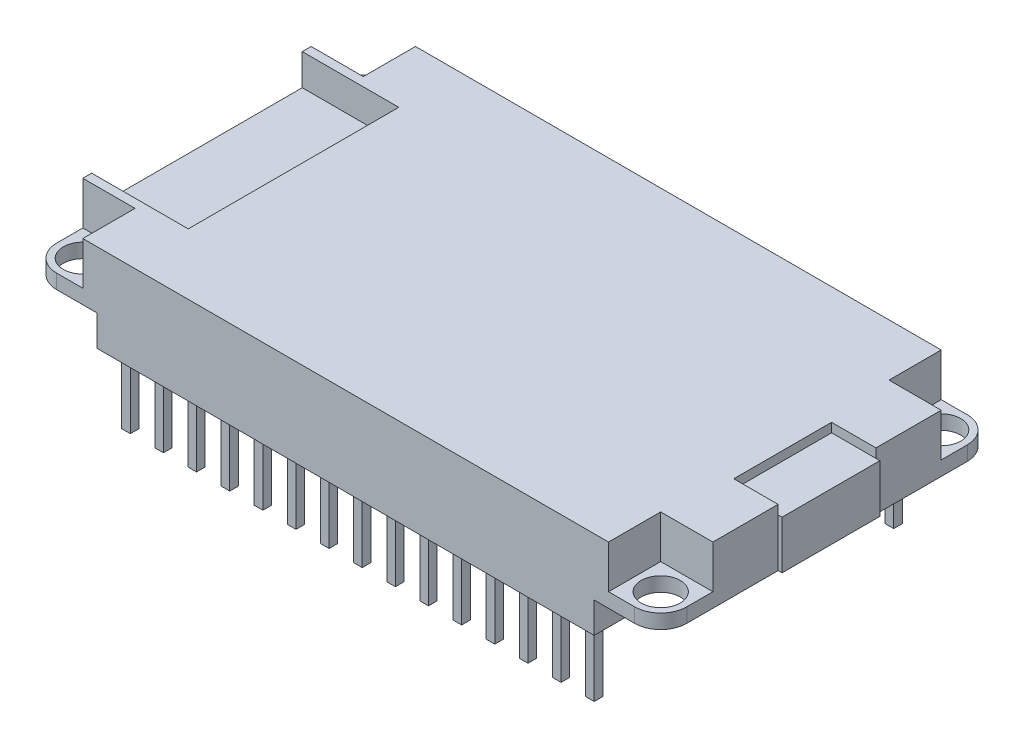
from build123d import *

# Parameters (mm, degrees)
SKETCH1_W           = 48.3
SKETCH1_H           = 25.5
SKETCH1_R           = 1.5
BOSS_EXTRUDE1_DEPTH = 4.4
FILLET1_R           = 2
SKETCH2_W           = 2.54
SKETCH2_H           = 2.54
BOSS_EXTRUDE2_DEPTH = 2.35
SKETCH3_W           = 0.66
SKETCH3_H           = 0.66
BOSS_EXTRUDE3_DEPTH = 5.33
SKETCH4_W           = 3.4
SKETCH4_H           = 7.5
CUT_EXTRUDE1_DEPTH  = 0.7
SKETCH5_W           = 7.5
SKETCH5_H           = 3.7
BOSS_EXTRUDE4_DEPTH = 0.3
SKETCH6_W           = 7.4
SKETCH6_H           = 16.14
CUT_EXTRUDE2_DEPTH  = 2.4
SKETCH7_W           = 4
SKETCH7_H           = 4
CUT_EXTRUDE3_DEPTH  = 3.3


with BuildPart() as part:
    # Sketch1 → Boss-Extrude1 (new body)
    with BuildSketch(Plane(origin=(0, 0, 0), x_dir=(1, 0, 0), z_dir=(0, 1, 0))):
        with Locations((24.15, -12.75)):
            Rectangle(SKETCH1_W, SKETCH1_H)
        with Locations((46.3, -2)):
            Circle(SKETCH1_R, mode=Mode.SUBTRACT)
        with Locations((2, -2)):
            Circle(SKETCH1_R, mode=Mode.SUBTRACT)
        with Locations((46.3, -23.5)):
            Circle(SKETCH1_R, mode=Mode.SUBTRACT)
        with Locations((2, -23.5)):
            Circle(SKETCH1_R, mode=Mode.SUBTRACT)
    extrude(amount=BOSS_EXTRUDE1_DEPTH)

    # Fillet1
    fillet1_edges = [part.edges().sort_by_distance(p)[0] for p in [
        (48.3, 2.2, 25.5),
        (0, 2.2, 25.5),
        (0, 2.2, 0),
        (48.3, 2.2, 0),
    ]]
    fillet(fillet1_edges, radius=FILLET1_R)

    # Sketch2 → Boss-Extrude2 (add)
    with BuildSketch(Plane.XZ):
        with Locations((6.37, 24.23)):
            Rectangle(SKETCH2_W, SKETCH2_H)
        with Locations((8.91, 24.23)):
            Rectangle(SKETCH2_W, SKETCH2_H)
        with Locations((11.45, 24.23)):
            Rectangle(SKETCH2_W, SKETCH2_H)
        with Locations((13.99, 24.23)):
            Rectangle(SKETCH2_W, SKETCH2_H)
        with Locations((16.53, 24.23)):
            Rectangle(SKETCH2_W, SKETCH2_H)
        with Locations((19.07, 24.23)):
            Rectangle(SKETCH2_W, SKETCH2_H)
        with Locations((21.61, 24.23)):
            Rectangle(SKETCH2_W, SKETCH2_H)
        with Locations((24.15, 24.23)):
            Rectangle(SKETCH2_W, SKETCH2_H)
        with Locations((26.69, 24.23)):
            Rectangle(SKETCH2_W, SKETCH2_H)
        with Locations((29.23, 24.23)):
            Rectangle(SKETCH2_W, SKETCH2_H)
        with Locations((31.77, 24.23)):
            Rectangle(SKETCH2_W, SKETCH2_H)
        with Locations((34.31, 24.23)):
            Rectangle(SKETCH2_W, SKETCH2_H)
        with Locations((36.85, 24.23)):
            Rectangle(SKETCH2_W, SKETCH2_H)
        with Locations((39.39, 24.23)):
            Rectangle(SKETCH2_W, SKETCH2_H)
        with Locations((41.93, 24.23)):
            Rectangle(SKETCH2_W, SKETCH2_H)
        with Locations((41.93, 1.27)):
            Rectangle(SKETCH2_W, SKETCH2_H)
        with Locations((39.39, 1.27)):
            Rectangle(SKETCH2_W, SKETCH2_H)
        with Locations((36.85, 1.27)):
            Rectangle(SKETCH2_W, SKETCH2_H)
        with Locations((34.31, 1.27)):
            Rectangle(SKETCH2_W, SKETCH2_H)
        with Locations((31.77, 1.27)):
            Rectangle(SKETCH2_W, SKETCH2_H)
        with Locations((29.23, 1.27)):
            Rectangle(SKETCH2_W, SKETCH2_H)
        with Locations((26.69, 1.27)):
            Rectangle(SKETCH2_W, SKETCH2_H)
        with Locations((24.15, 1.27)):
            Rectangle(SKETCH2_W, SKETCH2_H)
        with Locations((21.61, 1.27)):
            Rectangle(SKETCH2_W, SKETCH2_H)
        with Locations((19.07, 1.27)):
            Rectangle(SKETCH2_W, SKETCH2_H)
        with Locations((16.53, 1.27)):
            Rectangle(SKETCH2_W, SKETCH2_H)
        with Locations((13.99, 1.27)):
            Rectangle(SKETCH2_W, SKETCH2_H)
        with Locations((11.45, 1.27)):
            Rectangle(SKETCH2_W, SKETCH2_H)
        with Locations((8.91, 1.27)):
            Rectangle(SKETCH2_W, SKETCH2_H)
        with Locations((6.37, 1.27)):
            Rectangle(SKETCH2_W, SKETCH2_H)
    extrude(amount=BOSS_EXTRUDE2_DEPTH)

    # Sketch3 → Boss-Extrude3 (add)
    with BuildSketch(Plane.XZ.offset(2.35)):
        with Locations((6.37, 24.23)):
            Rectangle(SKETCH3_W, SKETCH3_H)
        with Locations((8.91, 24.23)):
            Rectangle(SKETCH3_W, SKETCH3_H)
        with Locations((11.45, 24.23)):
            Rectangle(SKETCH3_W, SKETCH3_H)
        with Locations((13.99, 24.23)):
            Rectangle(SKETCH3_W, SKETCH3_H)
        with Locations((16.53, 24.23)):
            Rectangle(SKETCH3_W, SKETCH3_H)
        with Locations((19.07, 24.23)):
            Rectangle(SKETCH3_W, SKETCH3_H)
        with Locations((21.61, 24.23)):
            Rectangle(SKETCH3_W, SKETCH3_H)
        with Locations((24.15, 24.23)):
            Rectangle(SKETCH3_W, SKETCH3_H)
        with Locations((26.69, 24.23)):
            Rectangle(SKETCH3_W, SKETCH3_H)
        with Locations((29.23, 24.23)):
            Rectangle(SKETCH3_W, SKETCH3_H)
        with Locations((31.77, 24.23)):
            Rectangle(SKETCH3_W, SKETCH3_H)
        with Locations((34.31, 24.23)):
            Rectangle(SKETCH3_W, SKETCH3_H)
        with Locations((36.85, 24.23)):
            Rectangle(SKETCH3_W, SKETCH3_H)
        with Locations((39.39, 24.23)):
            Rectangle(SKETCH3_W, SKETCH3_H)
        with Locations((41.93, 24.23)):
            Rectangle(SKETCH3_W, SKETCH3_H)
        with Locations((41.93, 1.27)):
            Rectangle(SKETCH3_W, SKETCH3_H)
        with Locations((39.39, 1.27)):
            Rectangle(SKETCH3_W, SKETCH3_H)
        with Locations((36.85, 1.27)):
            Rectangle(SKETCH3_W, SKETCH3_H)
        with Locations((34.31, 1.27)):
            Rectangle(SKETCH3_W, SKETCH3_H)
        with Locations((31.77, 1.27)):
            Rectangle(SKETCH3_W, SKETCH3_H)
        with Locations((29.23, 1.27)):
            Rectangle(SKETCH3_W, SKETCH3_H)
        with Locations((26.69, 1.27)):
            Rectangle(SKETCH3_W, SKETCH3_H)
        with Locations((24.15, 1.27)):
            Rectangle(SKETCH3_W, SKETCH3_H)
        with Locations((21.61, 1.27)):
            Rectangle(SKETCH3_W, SKETCH3_H)
        with Locations((19.07, 1.27)):
            Rectangle(SKETCH3_W, SKETCH3_H)
        with Locations((16.53, 1.27)):
            Rectangle(SKETCH3_W, SKETCH3_H)
        with Locations((13.99, 1.27)):
            Rectangle(SKETCH3_W, SKETCH3_H)
        with Locations((11.45, 1.27)):
            Rectangle(SKETCH3_W, SKETCH3_H)
        with Locations((8.91, 1.27)):
            Rectangle(SKETCH3_W, SKETCH3_H)
        with Locations((6.37, 1.27)):
            Rectangle(SKETCH3_W, SKETCH3_H)
    extrude(amount=BOSS_EXTRUDE3_DEPTH)

    # Sketch4 → Cut-Extrude1 (cut)
    with BuildSketch(Plane(origin=(0, 4.4, 0), x_dir=(1, 0, 0), z_dir=(0, 1, 0))):
        with Locations((46.6, -12.75)):
            Rectangle(SKETCH4_W, SKETCH4_H)
    extrude(amount=-CUT_EXTRUDE1_DEPTH, mode=Mode.SUBTRACT)

    # Sketch5 → Boss-Extrude4 (add)
    with BuildSketch(Plane(origin=(48.3, 0, 0), x_dir=(0, 0, -1), z_dir=(1, 0, 0))):
        with Locations((-12.75, 1.85)):
            Rectangle(SKETCH5_W, SKETCH5_H)
    extrude(amount=BOSS_EXTRUDE4_DEPTH)

    # Sketch6 → Cut-Extrude2 (cut)
    with BuildSketch(Plane(origin=(0, 4.4, 0), x_dir=(1, 0, 0), z_dir=(0, 1, 0))):
        with Locations((3.7, -12.75)):
            Rectangle(SKETCH6_W, SKETCH6_H)
    extrude(amount=-CUT_EXTRUDE2_DEPTH, mode=Mode.SUBTRACT)

    # Sketch7 → Cut-Extrude3 (cut)
    with BuildSketch(Plane(origin=(0, 4.4, 0), x_dir=(1, 0, 0), z_dir=(0, 1, 0))):
        with Locations((2, -2)):
            Rectangle(SKETCH7_W, SKETCH7_H)
        with Locations((46.3, -2)):
            Rectangle(SKETCH7_W, SKETCH7_H)
        with Locations((46.3, -23.5)):
            Rectangle(SKETCH7_W, SKETCH7_H)
        with Locations((2, -23.5)):
            Rectangle(SKETCH7_W, SKETCH7_H)
    extrude(amount=-CUT_EXTRUDE3_DEPTH, mode=Mode.SUBTRACT)


solid = part.part
